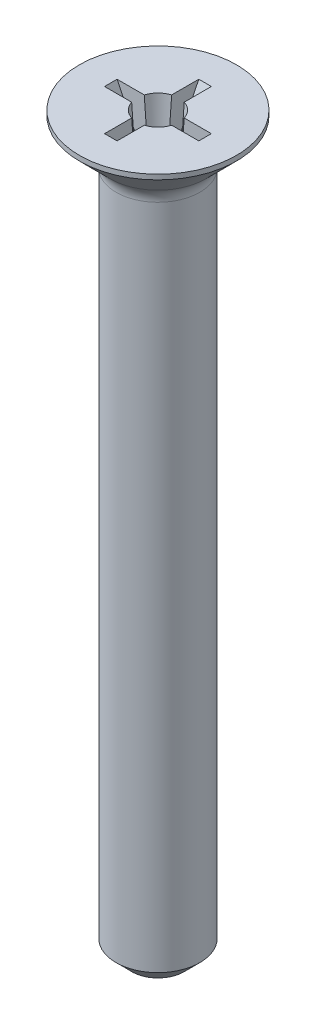
from build123d import *

# Parameters (mm, degrees)
CUT_EXTRUDE_2_DEPTH      = 0.12
CUT_EXTRUDE_2_DEPTH_BACK = 0.12
CUT_EXTRUDE_3_DEPTH      = 0.12
CUT_EXTRUDE_3_DEPTH_BACK = 0.12


with BuildPart() as part:
    # Эскиз1 → Повернуть1 (revolve)
    with BuildSketch(Plane.XY):
        with BuildLine():
            Line((0, 0), (-0.5, 0))
            Line((-0.5, 0), (-0.8, 0.3))
            Line((-0.8, 0.3), (-0.8, 13.04))
            ThreePointArc((-0.8, 13.04), (-0.830448187, 13.193073373), (-0.917157288, 13.322842712))
            Line((-0.917157288, 13.322842712), (-1.5, 13.905685425))
            Line((-1.5, 13.905685425), (-1.5, 14))
            Line((-1.5, 14), (-0.4, 14))
            Line((-0.4, 14), (-0.320283434, 12.86))
            Line((-0.320283434, 12.86), (0, 12.86))
            Line((0, 12.86), (0, 0))
        make_face()
    revolve(axis=Axis((0, 12.86, 0), (0, -1, 0)))

    # Эскиз3 → Вырез-Вытянуть2 (cut, two sides: drawn at the far end of the back side and taken through both)
    with BuildSketch(Plane.XY.offset(-CUT_EXTRUDE_2_DEPTH_BACK)):
        Polygon((-0.9, 14), (-0.343984849, 12.86), (0.343984849, 12.86), (0.9, 14), align=None)
    extrude(amount=CUT_EXTRUDE_2_DEPTH + CUT_EXTRUDE_2_DEPTH_BACK, mode=Mode.SUBTRACT)

    # Эскиз4 → Вырез-Вытянуть3 (cut, two sides: drawn at the far end of the back side and taken through both)
    with BuildSketch(Plane(origin=(0, 0, 0), x_dir=(0, 0, -1), z_dir=(1, 0, 0)).offset(-CUT_EXTRUDE_3_DEPTH_BACK)):
        Polygon((-0.343984849, 12.86), (-0.9, 14), (0.9, 14), (0.343984849, 12.86), align=None)
    extrude(amount=CUT_EXTRUDE_3_DEPTH + CUT_EXTRUDE_3_DEPTH_BACK, mode=Mode.SUBTRACT)


solid = part.part
